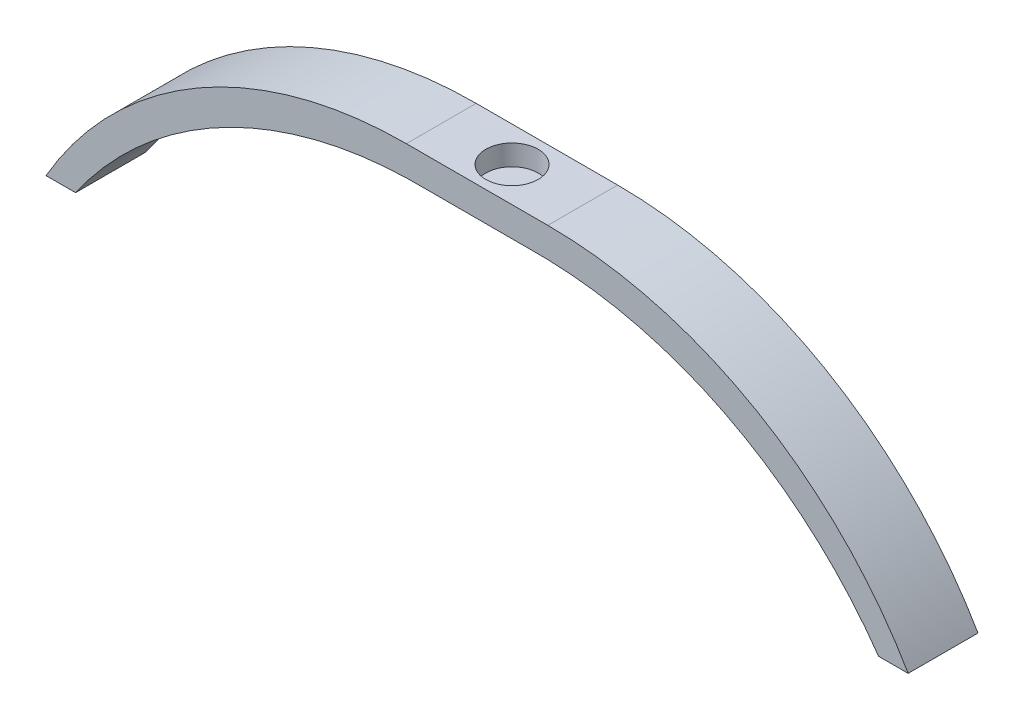
from build123d import *

# Parameters (mm, degrees)
SKETCH1_W           = 15.24
SKETCH1_H           = 10.16
BOSS_EXTRUDE1_DEPTH = 4.3
BOSS_EXTRUDE2_DEPTH = 10.16
SKETCH3_R           = 3.81
CUT_EXTRUDE1_DEPTH  = 3


with BuildPart() as part:
    # Sketch1 → Boss-Extrude1 (new body)
    with BuildSketch(Plane(origin=(0, 0, 0), x_dir=(1, 0, 0), z_dir=(0, 1, 0))):
        Rectangle(SKETCH1_W, SKETCH1_H)
    extrude(amount=BOSS_EXTRUDE1_DEPTH)

    # Sketch2 → Boss-Extrude2 (add)
    with BuildSketch(Plane.XY.offset(5.08)):
        with BuildLine():
            Line((7.62, 4.3), (7.62, 0))
            Line((7.62, 0), (10.29, -0.020216112))
            ThreePointArc((10.29, -0.020216112), (37.444945357, -7.24175572), (58.419152196, -25.94))
            Line((58.419152196, -25.94), (62.719152196, -25.94))
            ThreePointArc((62.719152196, -25.94), (40.552491636, -3.80185252), (10.29, 4.3))
            Line((10.29, 4.3), (7.62, 4.3))
        make_face()
        with BuildLine():
            ThreePointArc((-10.29, 4.3), (-40.552491636, -3.80185252), (-62.719152196, -25.94))
            Line((-62.719152196, -25.94), (-58.419152196, -25.94))
            ThreePointArc((-58.419152196, -25.94), (-37.444945357, -7.24175572), (-10.29, -0.020216112))
            Line((-10.29, -0.020216112), (-7.62, 0))
            Line((-7.62, 0), (-7.62, 4.3))
            Line((-7.62, 4.3), (-10.29, 4.3))
        make_face()
    extrude(amount=-BOSS_EXTRUDE2_DEPTH)

    # Sketch3 → Cut-Extrude1 (cut)
    with BuildSketch(Plane(origin=(0, 4.3, 0), x_dir=(1, 0, 0), z_dir=(0, 1, 0))):
        Circle(SKETCH3_R)
    extrude(amount=-CUT_EXTRUDE1_DEPTH, mode=Mode.SUBTRACT)


solid = part.part
